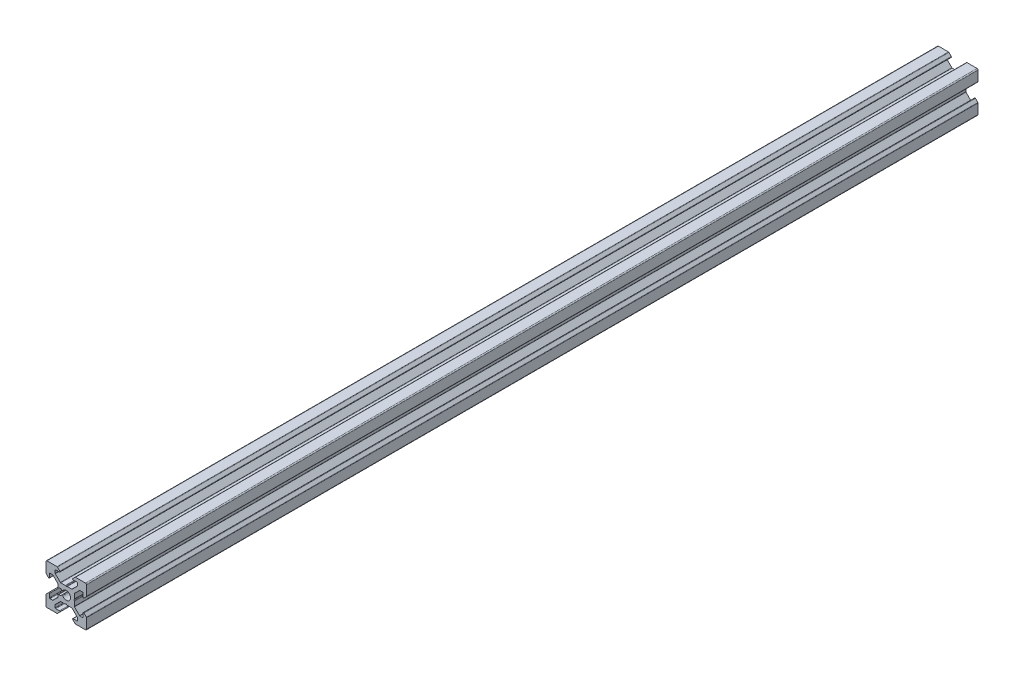
from build123d import *

# Parameters (mm, degrees)
BOSS_EXTRUDE1_DEPTH = 440


with BuildPart() as part:
    # Model → Boss-Extrude1 (new body)
    with BuildSketch(Plane.XY):
        with BuildLine():
            Line((2013.231211125, 1378.500393717), (2014.131175411, 1378.500393717))
            ThreePointArc((2014.131175411, 1378.500393717), (2014.245980441, 1378.523229857), (2014.343307446, 1378.588261683))
            Line((2014.343307446, 1378.588261683), (2014.688390533, 1378.93334477))
            ThreePointArc((2014.688390533, 1378.93334477), (2014.933942847, 1379.019345399), (2015.154358637, 1378.881110358))
            ThreePointArc((2015.154358637, 1378.881110358), (2019.031211125, 1380.000393717), (2015.154358637, 1381.119677076))
            ThreePointArc((2015.154358637, 1381.119677076), (2014.933942847, 1380.981442035), (2014.688390533, 1381.067442664))
            Line((2014.688390533, 1381.067442664), (2014.343307446, 1381.412525751))
            ThreePointArc((2014.343307446, 1381.412525751), (2014.245980441, 1381.477557577), (2014.131175412, 1381.500393717))
            Line((2014.131175412, 1381.500393717), (2013.231211125, 1381.500393717))
            ThreePointArc((2013.231211125, 1381.500393717), (2013.01907909, 1381.588261683), (2012.931211125, 1381.800393717))
            Line((2012.931211125, 1381.800393717), (2012.931211125, 1382.700358004))
            ThreePointArc((2012.931211125, 1382.700358004), (2012.908374985, 1382.815163033), (2012.843343159, 1382.912490038))
            Line((2012.843343159, 1382.912490038), (2010.378662785, 1385.377170412))
            ThreePointArc((2010.378662785, 1385.377170412), (2010.297556948, 1385.4313636), (2010.20188609, 1385.450393717))
            Line((2010.20188609, 1385.450393717), (2008.881211125, 1385.450393717))
            ThreePointArc((2008.881211125, 1385.450393717), (2008.70443443, 1385.377170412), (2008.631211125, 1385.200393717))
            Line((2008.631211125, 1385.200393717), (2008.631211125, 1383.350393717))
            ThreePointArc((2008.631211125, 1383.350393717), (2008.476881983, 1383.119423834), (2008.20443443, 1383.173617022))
            Line((2008.20443443, 1383.173617022), (2007.01907909, 1384.358972361))
            ThreePointArc((2007.01907909, 1384.358972361), (2006.954047265, 1384.456299366), (2006.931211125, 1384.571104395))
            Line((2006.931211125, 1384.571104395), (2006.931211125, 1389.500393717))
            ThreePointArc((2006.931211125, 1389.500393717), (2007.077657734, 1389.853947108), (2007.431211125, 1390.000393717))
            Line((2007.431211125, 1390.000393717), (2012.360500447, 1390.000393717))
            ThreePointArc((2012.360500447, 1390.000393717), (2012.475305476, 1389.977557577), (2012.572632481, 1389.912525752))
            Line((2012.572632481, 1389.912525752), (2013.75798782, 1388.727170412))
            ThreePointArc((2013.75798782, 1388.727170412), (2013.812181008, 1388.454722859), (2013.581211125, 1388.300393717))
            Line((2013.581211125, 1388.300393717), (2011.731211125, 1388.300393717))
            ThreePointArc((2011.731211125, 1388.300393717), (2011.55443443, 1388.227170412), (2011.481211125, 1388.050393717))
            Line((2011.481211125, 1388.050393717), (2011.481211125, 1386.729718752))
            ThreePointArc((2011.481211125, 1386.729718752), (2011.500241242, 1386.634047894), (2011.55443443, 1386.552942057))
            Line((2011.55443443, 1386.552942057), (2014.033759465, 1384.073617022))
            ThreePointArc((2014.033759465, 1384.073617022), (2014.114865302, 1384.019423834), (2014.21053616, 1384.000393717))
            Line((2014.21053616, 1384.000393717), (2016.470233902, 1384.000393717))
            ThreePointArc((2016.470233902, 1384.000393717), (2016.61325329, 1383.964108439), (2016.721676023, 1383.864030081))
            ThreePointArc((2016.721676023, 1383.864030081), (2016.931211125, 1383.750393717), (2017.140746226, 1383.864030081))
            ThreePointArc((2017.140746226, 1383.864030081), (2017.24916896, 1383.964108439), (2017.392188348, 1384.000393717))
            Line((2017.392188348, 1384.000393717), (2019.65188609, 1384.000393717))
            ThreePointArc((2019.65188609, 1384.000393717), (2019.747556948, 1384.019423834), (2019.828662785, 1384.073617022))
            Line((2019.828662785, 1384.073617022), (2022.30798782, 1386.552942057))
            ThreePointArc((2022.30798782, 1386.552942057), (2022.362181008, 1386.634047894), (2022.381211125, 1386.729718752))
            Line((2022.381211125, 1386.729718752), (2022.381211125, 1388.050393717))
            ThreePointArc((2022.381211125, 1388.050393717), (2022.30798782, 1388.227170412), (2022.131211125, 1388.300393717))
            Line((2022.131211125, 1388.300393717), (2020.281211125, 1388.300393717))
            ThreePointArc((2020.281211125, 1388.300393717), (2020.050241242, 1388.454722859), (2020.10443443, 1388.727170412))
            Line((2020.10443443, 1388.727170412), (2021.289789769, 1389.912525752))
            ThreePointArc((2021.289789769, 1389.912525752), (2021.387116773, 1389.977557577), (2021.501921803, 1390.000393717))
            Line((2021.501921803, 1390.000393717), (2026.431211125, 1390.000393717))
            ThreePointArc((2026.431211125, 1390.000393717), (2026.784764515, 1389.853947108), (2026.931211125, 1389.500393717))
            Line((2026.931211125, 1389.500393717), (2026.931211125, 1384.571104395))
            ThreePointArc((2026.931211125, 1384.571104395), (2026.908374985, 1384.456299366), (2026.843343159, 1384.358972361))
            Line((2026.843343159, 1384.358972361), (2025.65798782, 1383.173617022))
            ThreePointArc((2025.65798782, 1383.173617022), (2025.385540267, 1383.119423834), (2025.231211125, 1383.350393717))
            Line((2025.231211125, 1383.350393717), (2025.231211125, 1385.200393717))
            ThreePointArc((2025.231211125, 1385.200393717), (2025.15798782, 1385.377170412), (2024.981211125, 1385.450393717))
            Line((2024.981211125, 1385.450393717), (2023.66053616, 1385.450393717))
            ThreePointArc((2023.66053616, 1385.450393717), (2023.564865302, 1385.4313636), (2023.483759465, 1385.377170412))
            Line((2023.483759465, 1385.377170412), (2021.00443443, 1382.897845377))
            ThreePointArc((2021.00443443, 1382.897845377), (2020.950241242, 1382.81673954), (2020.931211125, 1382.721068682))
            Line((2020.931211125, 1382.721068682), (2020.931211125, 1380.46137094))
            ThreePointArc((2020.931211125, 1380.46137094), (2020.894925847, 1380.318351552), (2020.794847489, 1380.209928818))
            ThreePointArc((2020.794847489, 1380.209928818), (2020.681211125, 1380.000393717), (2020.794847488, 1379.790858616))
            ThreePointArc((2020.794847488, 1379.790858616), (2020.894925847, 1379.682435882), (2020.931211125, 1379.539416494))
            Line((2020.931211125, 1379.539416494), (2020.931211125, 1377.279718752))
            ThreePointArc((2020.931211125, 1377.279718752), (2020.950241242, 1377.184047894), (2021.00443443, 1377.102942057))
            Line((2021.00443443, 1377.102942057), (2023.483759465, 1374.623617022))
            ThreePointArc((2023.483759465, 1374.623617022), (2023.564865302, 1374.569423834), (2023.66053616, 1374.550393717))
            Line((2023.66053616, 1374.550393717), (2024.981211125, 1374.550393717))
            ThreePointArc((2024.981211125, 1374.550393717), (2025.15798782, 1374.623617022), (2025.231211125, 1374.800393717))
            Line((2025.231211125, 1374.800393717), (2025.231211125, 1376.650393717))
            ThreePointArc((2025.231211125, 1376.650393717), (2025.385540267, 1376.8813636), (2025.65798782, 1376.827170412))
            Line((2025.65798782, 1376.827170412), (2026.843343159, 1375.641815073))
            ThreePointArc((2026.843343159, 1375.641815073), (2026.908374985, 1375.544488069), (2026.931211125, 1375.429683039))
            Line((2026.931211125, 1375.429683039), (2026.931211125, 1370.500393717))
            ThreePointArc((2026.931211125, 1370.500393717), (2026.784764515, 1370.146840327), (2026.431211125, 1370.000393717))
            Line((2026.431211125, 1370.000393717), (2021.501921803, 1370.000393717))
            ThreePointArc((2021.501921803, 1370.000393717), (2021.387116773, 1370.023229857), (2021.289789769, 1370.088261683))
            Line((2021.289789769, 1370.088261683), (2020.10443443, 1371.273617022))
            ThreePointArc((2020.10443443, 1371.273617022), (2020.050241242, 1371.546064575), (2020.281211125, 1371.700393717))
            Line((2020.281211125, 1371.700393717), (2022.131211125, 1371.700393717))
            ThreePointArc((2022.131211125, 1371.700393717), (2022.30798782, 1371.773617022), (2022.381211125, 1371.950393717))
            Line((2022.381211125, 1371.950393717), (2022.381211125, 1373.271068682))
            ThreePointArc((2022.381211125, 1373.271068682), (2022.362181008, 1373.36673954), (2022.30798782, 1373.447845377))
            Line((2022.30798782, 1373.447845377), (2019.828662785, 1375.927170412))
            ThreePointArc((2019.828662785, 1375.927170412), (2019.747556948, 1375.9813636), (2019.65188609, 1376.000393717))
            Line((2019.65188609, 1376.000393717), (2017.392188348, 1376.000393717))
            ThreePointArc((2017.392188348, 1376.000393717), (2017.24916896, 1376.036678995), (2017.140746226, 1376.136757353))
            ThreePointArc((2017.140746226, 1376.136757353), (2016.931211125, 1376.250393717), (2016.721676023, 1376.136757354))
            ThreePointArc((2016.721676023, 1376.136757354), (2016.61325329, 1376.036678995), (2016.470233902, 1376.000393717))
            Line((2016.470233902, 1376.000393717), (2014.21053616, 1376.000393717))
            ThreePointArc((2014.21053616, 1376.000393717), (2014.114865302, 1375.9813636), (2014.033759465, 1375.927170412))
            Line((2014.033759465, 1375.927170412), (2011.55443443, 1373.447845377))
            ThreePointArc((2011.55443443, 1373.447845377), (2011.500241242, 1373.36673954), (2011.481211125, 1373.271068682))
            Line((2011.481211125, 1373.271068682), (2011.481211125, 1371.950393717))
            ThreePointArc((2011.481211125, 1371.950393717), (2011.55443443, 1371.773617022), (2011.731211125, 1371.700393717))
            Line((2011.731211125, 1371.700393717), (2013.581211125, 1371.700393717))
            ThreePointArc((2013.581211125, 1371.700393717), (2013.812181008, 1371.546064575), (2013.75798782, 1371.273617022))
            Line((2013.75798782, 1371.273617022), (2012.572632481, 1370.088261683))
            ThreePointArc((2012.572632481, 1370.088261683), (2012.475305476, 1370.023229857), (2012.360500447, 1370.000393717))
            Line((2012.360500447, 1370.000393717), (2007.431211125, 1370.000393717))
            ThreePointArc((2007.431211125, 1370.000393717), (2007.077657734, 1370.146840327), (2006.931211125, 1370.500393717))
            Line((2006.931211125, 1370.500393717), (2006.931211125, 1375.429683039))
            ThreePointArc((2006.931211125, 1375.429683039), (2006.954047265, 1375.544488069), (2007.01907909, 1375.641815073))
            Line((2007.01907909, 1375.641815073), (2008.20443443, 1376.827170412))
            ThreePointArc((2008.20443443, 1376.827170412), (2008.476881983, 1376.8813636), (2008.631211125, 1376.650393717))
            Line((2008.631211125, 1376.650393717), (2008.631211125, 1374.800393717))
            ThreePointArc((2008.631211125, 1374.800393717), (2008.70443443, 1374.623617022), (2008.881211125, 1374.550393717))
            Line((2008.881211125, 1374.550393717), (2010.20188609, 1374.550393717))
            ThreePointArc((2010.20188609, 1374.550393717), (2010.297556948, 1374.569423834), (2010.378662785, 1374.623617022))
            Line((2010.378662785, 1374.623617022), (2012.843343159, 1377.088297396))
            ThreePointArc((2012.843343159, 1377.088297396), (2012.908374985, 1377.185624401), (2012.931211125, 1377.300429431))
            Line((2012.931211125, 1377.300429431), (2012.931211125, 1378.200393717))
            ThreePointArc((2012.931211125, 1378.200393717), (2013.01907909, 1378.412525751), (2013.231211125, 1378.500393717))
        make_face()
    extrude(amount=BOSS_EXTRUDE1_DEPTH)


solid = part.part
